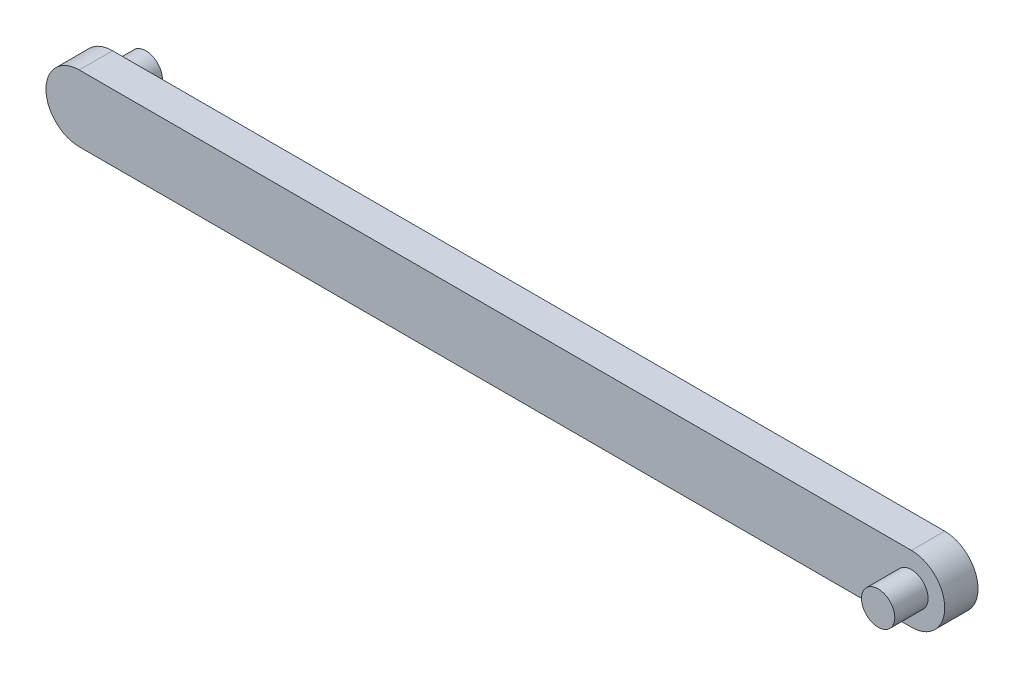
from build123d import *

# Parameters (mm, degrees)
EXTRUDE_1_DEPTH = 2
SKETCH_2_R      = 1
EXTRUDE_2_DEPTH = 2
SKETCH_3_R      = 1
EXTRUDE_3_DEPTH = 2


with BuildPart() as part:
    # 草图1 → 凸台-拉伸1 (new body)
    with BuildSketch(Plane.XY):
        with BuildLine():
            Line((-16.391109626, -2), (33.608890374, -2))
            ThreePointArc((33.608890374, -2), (35.608890374, 0), (33.608890374, 2))
            Line((33.608890374, 2), (-16.391109626, 2))
            ThreePointArc((-16.391109626, 2), (-18.391109626, 0), (-16.391109626, -2))
        make_face()
    extrude(amount=EXTRUDE_1_DEPTH)

    # 草图2 → 凸台-拉伸2 (add)
    with BuildSketch(Plane.XY.offset(2)):
        with Locations((33.608890374, 0)):
            Circle(SKETCH_2_R)
    extrude(amount=EXTRUDE_2_DEPTH)

    # 草图3 → 凸台-拉伸3 (add)
    with BuildSketch(Plane(origin=(0, 0, 0), x_dir=(-1, 0, 0), z_dir=(0, 0, -1))):
        with Locations((16.391109626, 0)):
            Circle(SKETCH_3_R)
    extrude(amount=EXTRUDE_3_DEPTH)


solid = part.part
